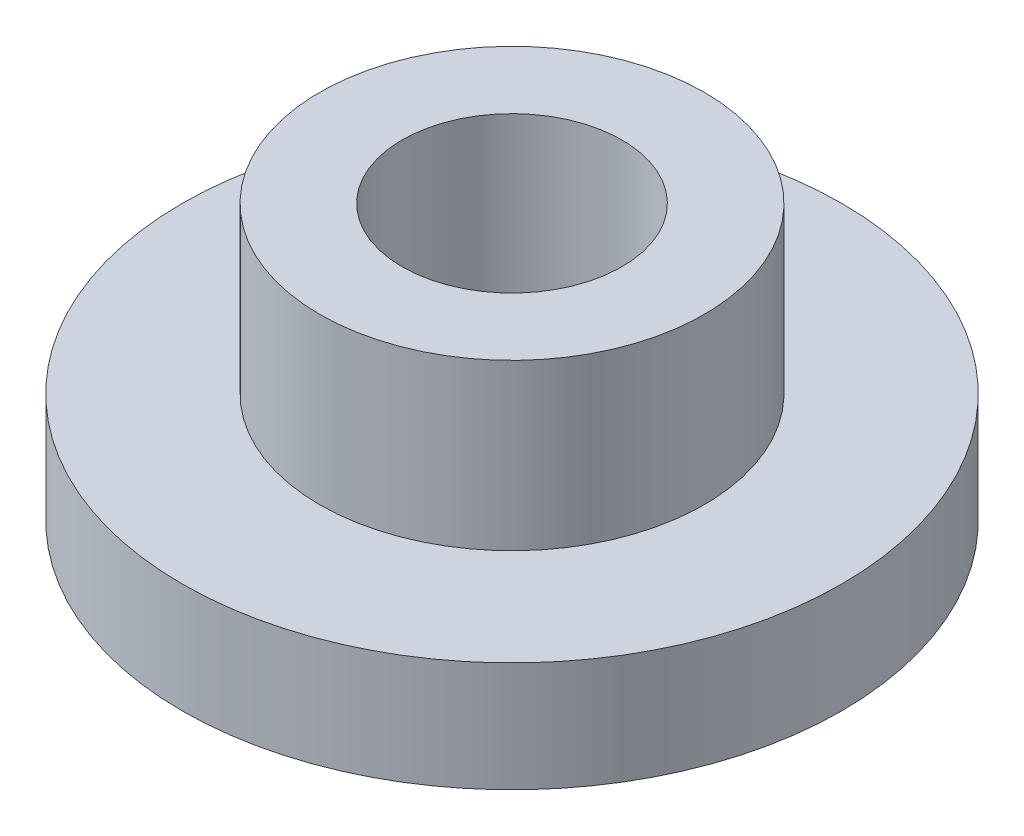
from build123d import *

# Parameters (mm, degrees)
SKETCH_1_R      = 3.5
SKETCH_1_R_2    = 2
EXTRUDE_1_DEPTH = 3
EXTRUDE_START   = -2
SKETCH_1_3_R    = 6
SKETCH_1_3_R_2  = 2
EXTRUDE_2_DEPTH = 2


with BuildPart() as part:
    # 草图1 → 凸台-拉伸1 (new body)
    with BuildSketch(Plane(origin=(0, 0, 0), x_dir=(1, 0, 0), z_dir=(0, 1, 0))):
        Circle(SKETCH_1_R)
        Circle(SKETCH_1_R_2, mode=Mode.SUBTRACT)
    extrude(amount=EXTRUDE_1_DEPTH)

    # 草图1<3> → 凸台-拉伸2 (add)
    with BuildSketch(Plane(origin=(0, 0, 0), x_dir=(1, 0, 0), z_dir=(0, 1, 0)).offset(EXTRUDE_START)):
        Circle(SKETCH_1_3_R)
        Circle(SKETCH_1_3_R_2, mode=Mode.SUBTRACT)
    extrude(amount=EXTRUDE_2_DEPTH)


solid = part.part
